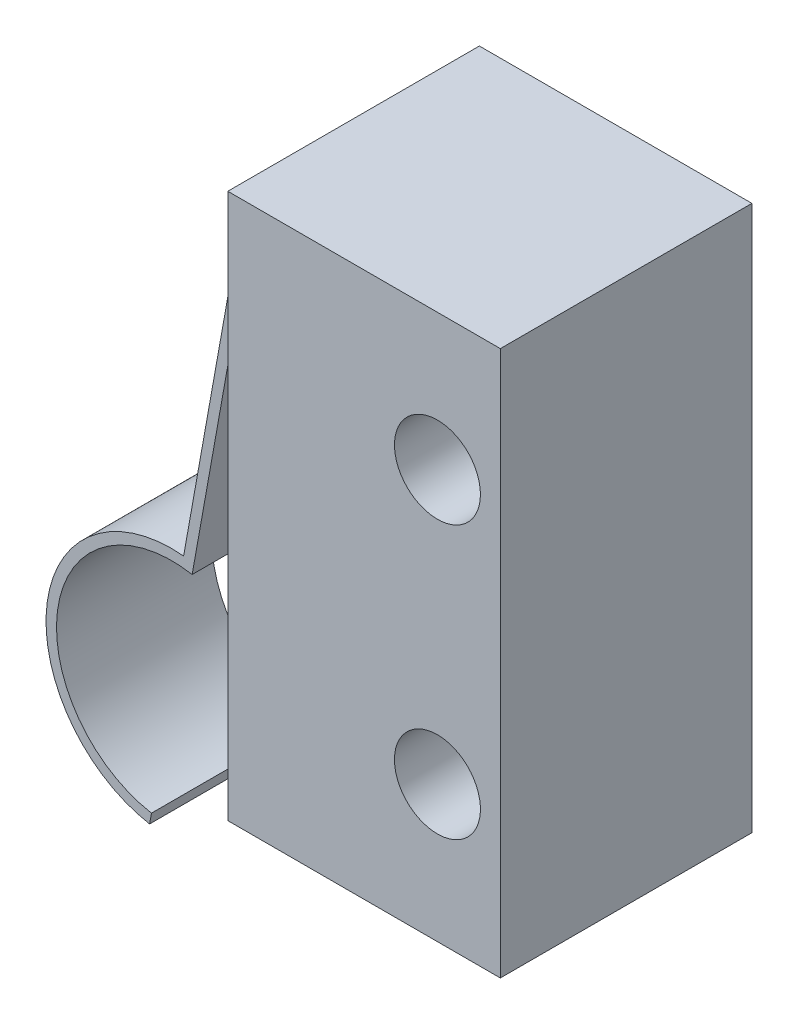
from build123d import *

# Parameters (mm, degrees)
SKETCH1_W           = 6.5
SKETCH1_H           = 13
BOSS_EXTRUDE1_DEPTH = 3
SKETCH4_R           = 1.025
CUT_EXTRUDE1_DEPTH  = 7
EXTRUDE_THIN1_DEPTH = 1.85


with BuildPart() as part:
    # Sketch1 → Boss-Extrude1 (new body, symmetric)
    with BuildSketch(Plane.XY):
        Rectangle(SKETCH1_W, SKETCH1_H)
    extrude(amount=BOSS_EXTRUDE1_DEPTH, both=True)

    # Sketch4 → Cut-Extrude1 (cut, through all)
    with BuildSketch(Plane.XY.offset(3)):
        with Locations((1.75, 3.25)):
            Circle(SKETCH4_R)
        with Locations((1.75, -3.25)):
            Circle(SKETCH4_R)
    extrude(amount=-CUT_EXTRUDE1_DEPTH, mode=Mode.SUBTRACT)

    # Sketch9 → Extrude-Thin1 (add, symmetric)
    with BuildSketch(Plane.XY):
        with BuildLine():
            Line((-3.25, 5.375), (-3.75, 5.375))
            Line((-3.75, 5.375), (-5.25, -2.991600265))
            ThreePointArc((-5.25, -2.991600265), (-8.44213538, -5.21314741), (-6.220588235, -8.40528279))
            Line((-6.220588235, -8.40528279), (-6.264705882, -8.651359268))
            ThreePointArc((-6.264705882, -8.651359268), (-8.707721009, -5.292635692), (-5.453800269, -2.711677189))
            Line((-5.453800269, -2.711677189), (-3.959165007, 5.625))
            Line((-3.959165007, 5.625), (-3.25, 5.625))
            Line((-3.25, 5.625), (-3.25, 5.375))
        make_face()
    extrude(amount=EXTRUDE_THIN1_DEPTH, both=True)


solid = part.part
